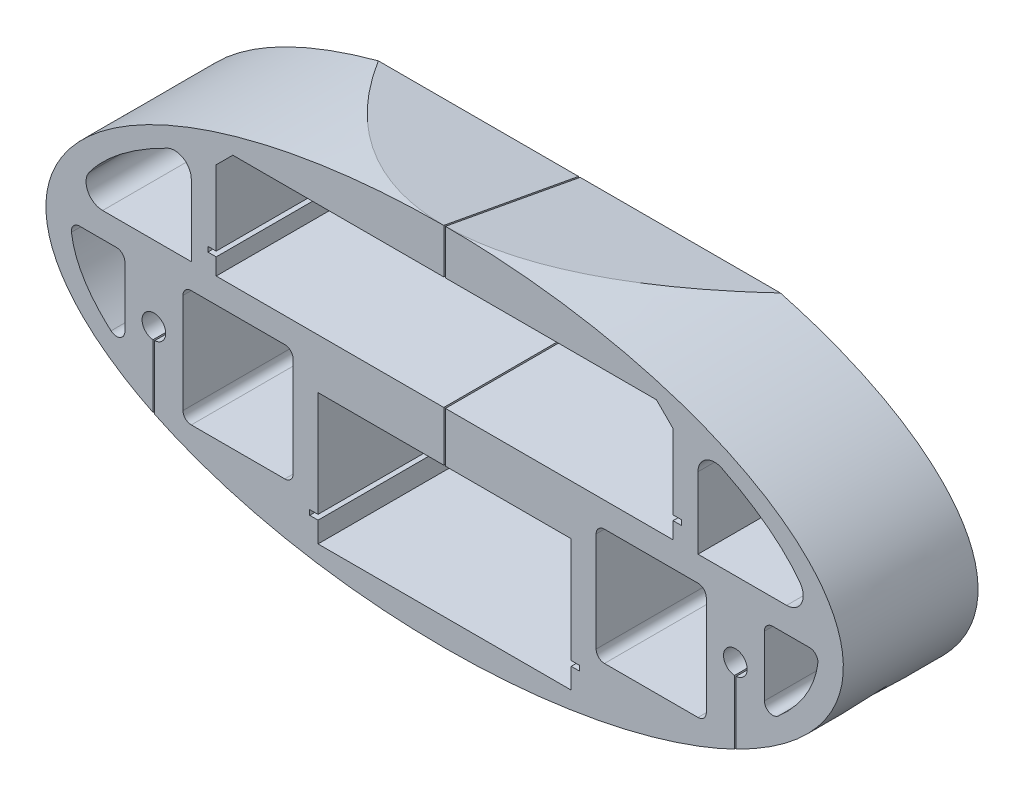
from build123d import *

# Parameters (mm, degrees)
SKETCH1_RX               = 240
SKETCH1_RY               = 110
BOSS_EXTRUDE1_DEPTH      = 81.0825
CUT_EXTRUDE5_DEPTH       = 82.0825
SKETCH12_R               = 7.11696595
CUT_EXTRUDE8_DEPTH       = 82.0825
CUT_EXTRUDE9_DEPTH       = 241
CUT_EXTRUDE9_DEPTH_BACK  = 241
CUT_EXTRUDE14_DEPTH      = 1.000000698
CUT_EXTRUDE14_DEPTH_BACK = 82.0825001
SKETCH15_W               = 66.3
SKETCH15_H               = 70
CUT_EXTRUDE16_DEPTH      = 1.000000698
CUT_EXTRUDE16_DEPTH_BACK = 82.0825001
SKETCH16_W               = 1
SKETCH16_H               = 45.520413792
SKETCH16_H_2             = 125
CUT_EXTRUDE17_DEPTH      = 1.000000698
CUT_EXTRUDE17_DEPTH_BACK = 82.0825001
FILLET1_R                = 10
FILLET3_R                = 5
CHAMFER1_SIZE            = 10


with BuildPart() as part:
    # Sketch1 → Boss-Extrude1 (new body)
    with BuildSketch(Plane.XY):
        with Locations((0, 0)):
            Ellipse(SKETCH1_RX, SKETCH1_RY)
    extrude(amount=-BOSS_EXTRUDE1_DEPTH)

    # Sketch10 → Cut-Extrude5 (cut, through all)
    with BuildSketch(Plane.XY):
        Polygon((-137.5, 83.1), (137.5, 83.1), (137.5, 28.1), (142.5, 28.1), (142.5, 25.1), (137.5, 25.1), (137.5, 15.1), (-137.5, 15.1), (-137.5, 25.1), (-142.5, 25.1), (-142.5, 28.1), (-137.5, 28.1), align=None)
    extrude(amount=-CUT_EXTRUDE5_DEPTH, mode=Mode.SUBTRACT)

    # Sketch12 → Cut-Extrude8 (cut, through all)
    with BuildSketch(Plane.XY):
        with Locations((175, -30)):
            Circle(SKETCH12_R)
        with Locations((-175, -30)):
            Circle(SKETCH12_R)
    extrude(amount=-CUT_EXTRUDE8_DEPTH, mode=Mode.SUBTRACT)

    # Sketch14 → Cut-Extrude9 (cut, two sides)
    with BuildSketch(Plane(origin=(0, 0, 0), x_dir=(0, 0, -1), z_dir=(1, 0, 0))) as cut_extrude9_sk:
        Polygon((0, 110), (81.0825, 95), (81.0825, 110), align=None)
        Polygon((0, -110), (81.0825, -105), (81.0825, -110), align=None)
    extrude(amount=CUT_EXTRUDE9_DEPTH, mode=Mode.SUBTRACT)
    extrude(cut_extrude9_sk.sketch, amount=-CUT_EXTRUDE9_DEPTH_BACK, mode=Mode.SUBTRACT)

    # Sketch21 → Cut-Extrude14 (cut, two sides)
    with BuildSketch(Plane.XY) as cut_extrude14_sk:
        Polygon((76.2, -81.5), (76.2, -93.9), (-76.2, -93.9), (-76.2, -81.5), (-81.2, -81.5), (-81.2, -78.5), (-76.2, -78.5), (-76.2, -15), (76.2, -15), (76.2, -78.5), (81.2, -78.5), (81.2, -81.5), align=None)
    extrude(amount=CUT_EXTRUDE14_DEPTH, mode=Mode.SUBTRACT)
    extrude(cut_extrude14_sk.sketch, amount=-CUT_EXTRUDE14_DEPTH_BACK, mode=Mode.SUBTRACT)

    # Sketch15 → Cut-Extrude16 (cut, two sides)
    with BuildSketch(Plane.XY) as cut_extrude16_sk:
        with BuildLine():
            Line((152.5, 73.52668114), (152.5, 15.1))
            Line((152.5, 15.1), (222.420096608, 15.1))
            add(Edge.make_bspline(
                [(222.420096608, 15.1), (210.507279325, 49.76143368), (152.5, 73.52668114)],
                knots=[0.151579794, 0.151579794, 0.151579794, 0.826060253, 0.826060253, 0.826060253], degree=2, weights=[1, 0.943671422, 1]))
        make_face()
        with BuildLine():
            Line((-192.5, -51.771101143), (-192.5, 0))
            Line((-192.5, 0), (-225, 0))
            add(Edge.make_bspline(
                [(-225, 0), (-225, -27.90059343), (-192.5, -51.771101143)],
                knots=[3.141592654, 3.141592654, 3.141592654, 3.685765991, 3.685765991, 3.685765991], degree=2, weights=[1, 0.963212218, 1]))
        make_face()
        with BuildLine():
            Line((192.5, -51.771101143), (192.5, 0))
            Line((192.5, 0), (225, 0))
            add(Edge.make_bspline(
                [(192.5, -51.771101143), (225, -27.90059343), (225, 0)],
                knots=[5.73901197, 5.73901197, 5.73901197, 6.283185307, 6.283185307, 6.283185307], degree=2, weights=[1, 0.963212218, 1]))
        make_face()
        with BuildLine():
            Line((-152.5, 15.1), (-222.420096608, 15.1))
            add(Edge.make_bspline(
                [(-152.5, 73.52668114), (-210.507279325, 49.76143368), (-222.420096608, 15.1)],
                knots=[2.3155324, 2.3155324, 2.3155324, 2.99001286, 2.99001286, 2.99001286], degree=2, weights=[1, 0.943671422, 1]))
            Line((-152.5, 73.52668114), (-152.5, 15.1))
        make_face()
        with Locations((124.35, -35)):
            Rectangle(SKETCH15_W, SKETCH15_H)
        with Locations((-124.35, -35)):
            Rectangle(SKETCH15_W, SKETCH15_H)
    extrude(amount=CUT_EXTRUDE16_DEPTH, mode=Mode.SUBTRACT)
    extrude(cut_extrude16_sk.sketch, amount=-CUT_EXTRUDE16_DEPTH_BACK, mode=Mode.SUBTRACT)

    # Sketch16 → Cut-Extrude17 (cut, two sides)
    with BuildSketch(Plane.XY) as cut_extrude17_sk:
        with Locations((175, -52.760206896)):
            Rectangle(SKETCH16_W, SKETCH16_H)
        with Locations((-175, -52.760206896)):
            Rectangle(SKETCH16_W, SKETCH16_H)
        with Locations((0, 47.5)):
            Rectangle(SKETCH16_W, SKETCH16_H_2)
    extrude(amount=CUT_EXTRUDE17_DEPTH, mode=Mode.SUBTRACT)
    extrude(cut_extrude17_sk.sketch, amount=-CUT_EXTRUDE17_DEPTH_BACK, mode=Mode.SUBTRACT)

    # Fillet1
    fillet1_edges = [part.edges().sort_by_distance(p)[0] for p in [
        (222.420096608, 15.1, -40.54125),
        (152.5, 73.52668114, -40.54125),
        (-222.420096608, 15.1, -40.54125),
        (-152.5, 73.52668114, -40.54125),
    ]]
    fillet(fillet1_edges, radius=FILLET1_R)

    # Fillet3
    fillet3_edges = [part.edges().sort_by_distance(p)[0] for p in [
        (192.5, 0, -40.54125),
        (-192.5, -51.771101143, -40.54125),
        (-225, 0, -40.54125),
        (-192.5, 0, -40.54125),
        (192.5, -51.771101143, -40.54125),
        (225, 0, -40.54125),
        (91.2, -70, -40.54125),
        (-157.5, -70, -40.54125),
        (-91.2, -70, -40.54125),
        (157.5, -70, -40.54125),
        (157.5, 0, -40.54125),
        (-91.2, 0, -40.54125),
        (91.2, 0, -40.54125),
        (-157.5, 0, -40.54125),
    ]]
    fillet(fillet3_edges, radius=FILLET3_R)

    # Chamfer1
    chamfer1_edges = [part.edges().sort_by_distance(p)[0] for p in [
        (-137.5, 83.1, -40.54125),
        (137.5, 83.1, -40.54125),
    ]]
    chamfer(chamfer1_edges, length=CHAMFER1_SIZE)


solid = part.part
